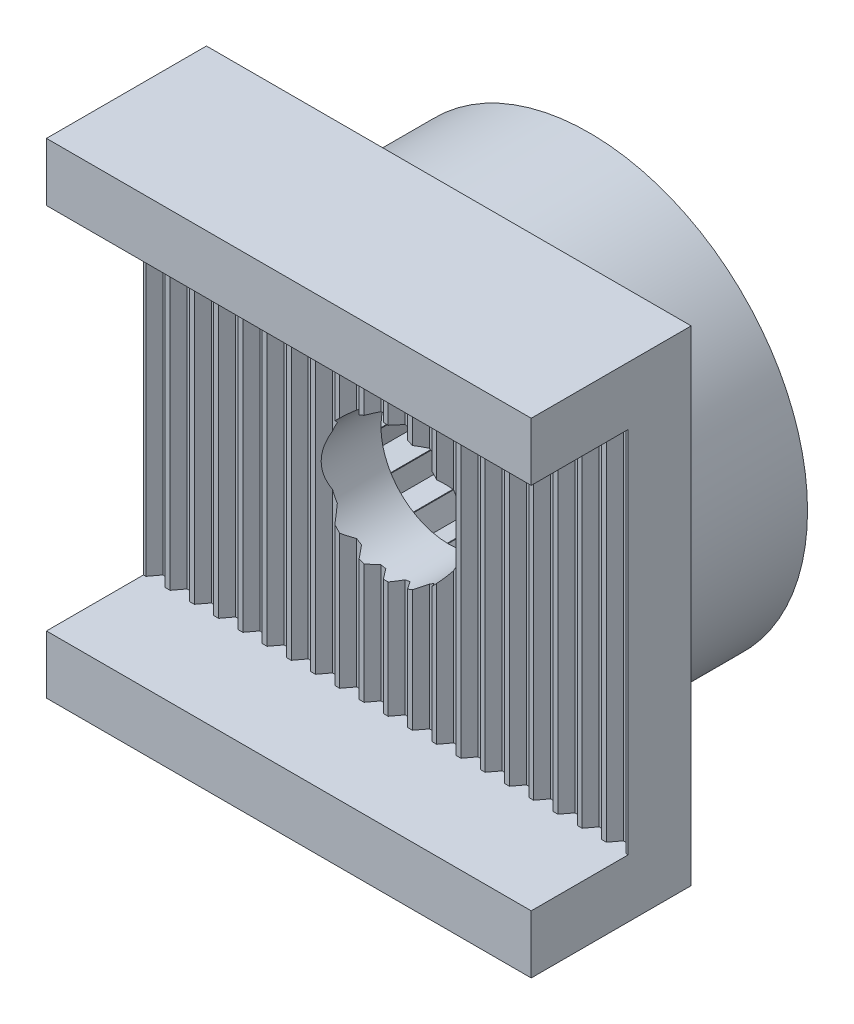
from build123d import *

# Parameters (mm, degrees)
ESQUISSE1_R                = 4.5
BOSS_EXTRU_1_DEPTH         = 2.9
ESQUISSE2_W                = 10
ESQUISSE2_H                = 10
ESQUISSE2_R                = 1.4
BOSS_EXTRU_2_DEPTH         = 1.3
ESQUISSE3_W                = 10
ESQUISSE3_H                = 1.2
BOSS_EXTRU_3_DEPTH         = 2
ENL_V_MAT_EXTRU_1_DEPTH    = 7.6
R_P_TITION_LIN_AIRE4_COUNT = 20
R_P_TITION_LIN_AIRE4_PITCH = 0.5


with BuildPart() as part:
    # Esquisse1 → Boss.-Extru.1 (new body)
    with BuildSketch(Plane.XY):
        Circle(ESQUISSE1_R)
        Polygon((2.011577371, -1.550856692), (2.011577371, -2.011577371), (1.550856692, -2.011577371), (1.541643286, -2.018647066), (1.4224, -2.463669069), (0.977377998, -2.344425783), (0.966648759, -2.348869979), (0.73628842, -2.747865791), (0.337292608, -2.517505451), (0.325778716, -2.519021284), (0, -2.8448), (-0.325778716, -2.519021284), (-0.337292608, -2.517505451), (-0.73628842, -2.747865791), (-0.966648759, -2.348869979), (-0.977377998, -2.344425783), (-1.4224, -2.463669069), (-1.541643286, -2.018647066), (-1.550856692, -2.011577371), (-2.011577371, -2.011577371), (-2.011577371, -1.550856692), (-2.018647066, -1.541643286), (-2.463669069, -1.4224), (-2.344425783, -0.977377998), (-2.348869979, -0.966648759), (-2.747865791, -0.73628842), (-2.517505451, -0.337292608), (-2.519021284, -0.325778716), (-2.8448, 0), (-2.519021284, 0.325778716), (-2.517505451, 0.337292608), (-2.747865791, 0.73628842), (-2.348869979, 0.966648759), (-2.344425783, 0.977377998), (-2.463669069, 1.4224), (-2.018647066, 1.541643286), (-2.011577371, 1.550856692), (-2.011577371, 2.011577371), (-1.550856692, 2.011577371), (-1.541643286, 2.018647066), (-1.4224, 2.463669069), (-0.977377998, 2.344425783), (-0.966648759, 2.348869979), (-0.73628842, 2.747865791), (-0.337292608, 2.517505451), (-0.325778716, 2.519021284), (0, 2.8448), (0.325778716, 2.519021284), (0.337292608, 2.517505451), (0.73628842, 2.747865791), (0.966648759, 2.348869979), (0.977377998, 2.344425783), (1.4224, 2.463669069), (1.541643286, 2.018647066), (1.550856692, 2.011577371), (2.011577371, 2.011577371), (2.011577371, 1.550856692), (2.018647066, 1.541643286), (2.463669069, 1.4224), (2.344425783, 0.977377998), (2.348869979, 0.966648759), (2.747865791, 0.73628842), (2.517505451, 0.337292608), (2.519021284, 0.325778716), (2.8448, 0), (2.519021284, -0.325778716), (2.517505451, -0.337292608), (2.747865791, -0.73628842), (2.348869979, -0.966648759), (2.344425783, -0.977377998), (2.463669069, -1.4224), (2.018647066, -1.541643286), align=None, mode=Mode.SUBTRACT)
    extrude(amount=BOSS_EXTRU_1_DEPTH)

    # Esquisse2 → Boss.-Extru.2 (add)
    with BuildSketch(Plane.XY.offset(2.9)):
        Rectangle(ESQUISSE2_W, ESQUISSE2_H)
        Circle(ESQUISSE2_R, mode=Mode.SUBTRACT)
    extrude(amount=BOSS_EXTRU_2_DEPTH)

    # Esquisse3 → Boss.-Extru.3 (add)
    with BuildSketch(Plane.XY.offset(4.2)):
        with Locations((0, 4.4)):
            Rectangle(ESQUISSE3_W, ESQUISSE3_H)
        with Locations((0, -4.4)):
            Rectangle(ESQUISSE3_W, ESQUISSE3_H)
    extrude(amount=BOSS_EXTRU_3_DEPTH)

    # Esquisse4 → Enlèv. mat.-Extru.1 (cut)
    with BuildSketch(Plane.XZ.offset(-3.8)):
        Polygon((-4.55, 4.2), (-4.7, 4), (-4.8, 4), (-4.95, 4.2), align=None)
    enl_v_mat_extru_1 = extrude(amount=ENL_V_MAT_EXTRU_1_DEPTH, mode=Mode.SUBTRACT)

    # Répétition linéaire4: Enlèv. mat.-Extru.1 ×20
    with Locations(*[(i * R_P_TITION_LIN_AIRE4_PITCH, 0, 0) for i in range(1, R_P_TITION_LIN_AIRE4_COUNT)]):
        add(enl_v_mat_extru_1, mode=Mode.SUBTRACT)


solid = part.part
